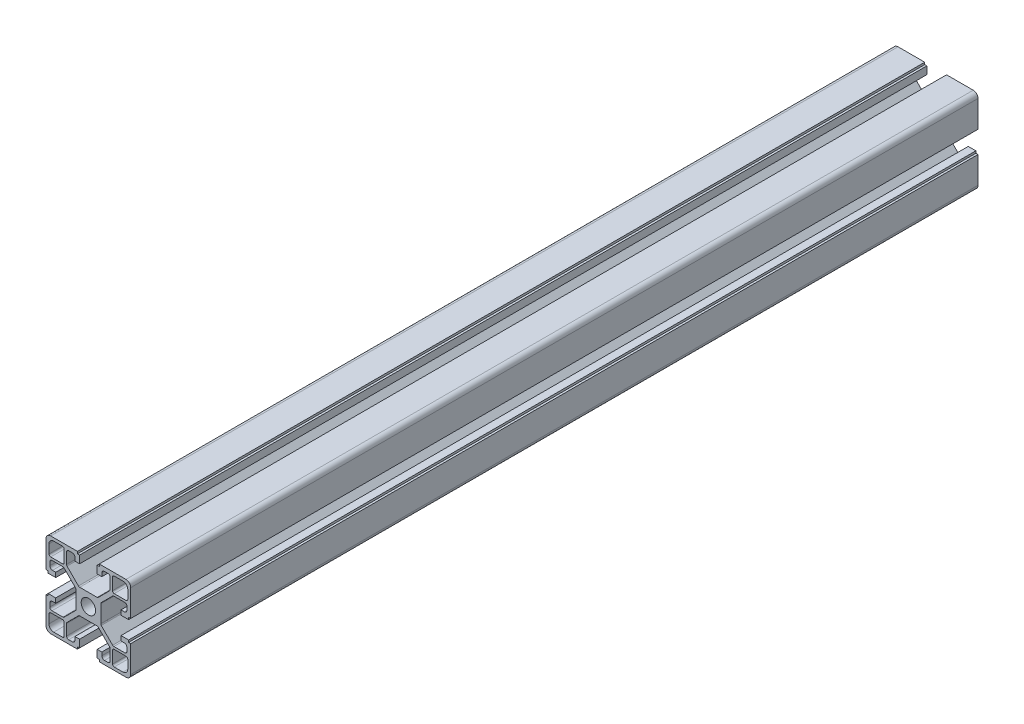
from build123d import *

# Parameters (mm, degrees)
SKETCH1_R           = 3.4
BOSS_EXTRUDE1_DEPTH = 400


with BuildPart() as part:
    # Sketch1 → Boss-Extrude1 (new body)
    with BuildSketch(Plane.XY):
        with BuildLine():
            Line((20, 17.75), (20, 5.15))
            Line((20, 5.15), (19, 5.15))
            Line((19, 5.15), (19, 4.15))
            Line((19, 4.15), (15.4, 4.15))
            Line((15.4, 4.15), (15.4, 6.35))
            Line((15.4, 6.35), (16.95, 6.35))
            ThreePointArc((16.95, 6.35), (17.833883476, 6.716116524), (18.2, 7.6))
            Line((18.2, 7.6), (18.2, 9.3))
            ThreePointArc((18.2, 9.3), (17.907106781, 10.007106781), (17.2, 10.3))
            Line((17.2, 10.3), (12.03669957, 10.3))
            ThreePointArc((12.03669957, 10.3), (11.73040037, 10.239040459), (11.470780817, 10.065452001))
            Line((11.470780817, 10.065452001), (6.084081247, 4.674305984))
            ThreePointArc((6.084081247, 4.674305984), (5.910833239, 4.414848262), (5.85, 4.108853983))
            Line((5.85, 4.108853983), (5.85, -4.108853983))
            ThreePointArc((5.85, -4.108853983), (5.910833239, -4.414848262), (6.084081247, -4.674305984))
            Line((6.084081247, -4.674305984), (11.470780817, -10.065452001))
            ThreePointArc((11.470780817, -10.065452001), (11.73040037, -10.239040459), (12.03669957, -10.3))
            Line((12.03669957, -10.3), (17.2, -10.3))
            ThreePointArc((17.2, -10.3), (17.907106781, -10.007106781), (18.2, -9.3))
            Line((18.2, -9.3), (18.2, -7.6))
            ThreePointArc((18.2, -7.6), (17.833883476, -6.716116524), (16.95, -6.35))
            Line((16.95, -6.35), (15.4, -6.35))
            Line((15.4, -6.35), (15.4, -4.15))
            Line((15.4, -4.15), (19, -4.15))
            Line((19, -4.15), (19, -5.15))
            Line((19, -5.15), (20, -5.15))
            Line((20, -5.15), (20, -17.75))
            ThreePointArc((20, -17.75), (19.340990258, -19.340990258), (17.75, -20))
            Line((17.75, -20), (5.15, -20))
            Line((5.15, -20), (5.15, -19))
            Line((5.15, -19), (4.15, -19))
            Line((4.15, -19), (4.15, -15.4))
            Line((4.15, -15.4), (6.35, -15.4))
            Line((6.35, -15.4), (6.35, -16.95))
            ThreePointArc((6.35, -16.95), (6.716116524, -17.833883476), (7.6, -18.2))
            Line((7.6, -18.2), (9.3, -18.2))
            ThreePointArc((9.3, -18.2), (10.007106781, -17.907106781), (10.3, -17.2))
            Line((10.3, -17.2), (10.3, -12.054477022))
            ThreePointArc((10.3, -12.054477022), (10.239166761, -11.748482743), (10.065918753, -11.489025021))
            Line((10.065918753, -11.489025021), (4.665899173, -6.084547999))
            ThreePointArc((4.665899173, -6.084547999), (4.406279619, -5.910959541), (4.09998042, -5.85))
            Line((4.09998042, -5.85), (-4.09998042, -5.85))
            ThreePointArc((-4.09998042, -5.85), (-4.406279619, -5.910959541), (-4.665899173, -6.084547999))
            Line((-4.665899173, -6.084547999), (-10.065918753, -11.489025021))
            ThreePointArc((-10.065918753, -11.489025021), (-10.239166761, -11.748482743), (-10.3, -12.054477022))
            Line((-10.3, -12.054477022), (-10.3, -17.2))
            ThreePointArc((-10.3, -17.2), (-10.007106781, -17.907106781), (-9.3, -18.2))
            Line((-9.3, -18.2), (-7.6, -18.2))
            ThreePointArc((-7.6, -18.2), (-6.716116524, -17.833883476), (-6.35, -16.95))
            Line((-6.35, -16.95), (-6.35, -15.4))
            Line((-6.35, -15.4), (-4.15, -15.4))
            Line((-4.15, -15.4), (-4.15, -19))
            Line((-4.15, -19), (-5.15, -19))
            Line((-5.15, -19), (-5.15, -20))
            Line((-5.15, -20), (-17.75, -20))
            ThreePointArc((-17.75, -20), (-19.340990258, -19.340990258), (-20, -17.75))
            Line((-20, -17.75), (-20, -5.15))
            Line((-20, -5.15), (-19, -5.15))
            Line((-19, -5.15), (-19, -4.15))
            Line((-19, -4.15), (-15.4, -4.15))
            Line((-15.4, -4.15), (-15.4, -6.35))
            Line((-15.4, -6.35), (-16.95, -6.35))
            ThreePointArc((-16.95, -6.35), (-17.833883476, -6.716116524), (-18.2, -7.6))
            Line((-18.2, -7.6), (-18.2, -9.3))
            ThreePointArc((-18.2, -9.3), (-17.907106781, -10.007106781), (-17.2, -10.3))
            Line((-17.2, -10.3), (-12.03669957, -10.3))
            ThreePointArc((-12.03669957, -10.3), (-11.73040037, -10.239040459), (-11.470780817, -10.065452001))
            Line((-11.470780817, -10.065452001), (-6.084081247, -4.674305984))
            ThreePointArc((-6.084081247, -4.674305984), (-5.910833239, -4.414848262), (-5.85, -4.108853983))
            Line((-5.85, -4.108853983), (-5.85, 4.108853983))
            ThreePointArc((-5.85, 4.108853983), (-5.910833239, 4.414848262), (-6.084081247, 4.674305984))
            Line((-6.084081247, 4.674305984), (-11.470780817, 10.065452001))
            ThreePointArc((-11.470780817, 10.065452001), (-11.73040037, 10.239040459), (-12.03669957, 10.3))
            Line((-12.03669957, 10.3), (-17.2, 10.3))
            ThreePointArc((-17.2, 10.3), (-17.907106781, 10.007106781), (-18.2, 9.3))
            Line((-18.2, 9.3), (-18.2, 7.6))
            ThreePointArc((-18.2, 7.6), (-17.833883476, 6.716116524), (-16.95, 6.35))
            Line((-16.95, 6.35), (-15.4, 6.35))
            Line((-15.4, 6.35), (-15.4, 4.15))
            Line((-15.4, 4.15), (-19, 4.15))
            Line((-19, 4.15), (-19, 5.15))
            Line((-19, 5.15), (-20, 5.15))
            Line((-20, 5.15), (-20, 17.75))
            ThreePointArc((-20, 17.75), (-19.340990258, 19.340990258), (-17.75, 20))
            Line((-17.75, 20), (-5.15, 20))
            Line((-5.15, 20), (-5.15, 19))
            Line((-5.15, 19), (-4.15, 19))
            Line((-4.15, 19), (-4.15, 15.4))
            Line((-4.15, 15.4), (-6.35, 15.4))
            Line((-6.35, 15.4), (-6.35, 16.95))
            ThreePointArc((-6.35, 16.95), (-6.716116524, 17.833883476), (-7.6, 18.2))
            Line((-7.6, 18.2), (-9.3, 18.2))
            ThreePointArc((-9.3, 18.2), (-10.007106781, 17.907106781), (-10.3, 17.2))
            Line((-10.3, 17.2), (-10.3, 12.054477022))
            ThreePointArc((-10.3, 12.054477022), (-10.239166761, 11.748482743), (-10.065918753, 11.489025021))
            Line((-10.065918753, 11.489025021), (-4.665899173, 6.084547999))
            ThreePointArc((-4.665899173, 6.084547999), (-4.406279619, 5.910959541), (-4.09998042, 5.85))
            Line((-4.09998042, 5.85), (4.09998042, 5.85))
            ThreePointArc((4.09998042, 5.85), (4.406279619, 5.910959541), (4.665899173, 6.084547999))
            Line((4.665899173, 6.084547999), (10.065918753, 11.489025021))
            ThreePointArc((10.065918753, 11.489025021), (10.239166761, 11.748482743), (10.3, 12.054477022))
            Line((10.3, 12.054477022), (10.3, 17.2))
            ThreePointArc((10.3, 17.2), (10.007106781, 17.907106781), (9.3, 18.2))
            Line((9.3, 18.2), (7.6, 18.2))
            ThreePointArc((7.6, 18.2), (6.716116524, 17.833883476), (6.35, 16.95))
            Line((6.35, 16.95), (6.35, 15.4))
            Line((6.35, 15.4), (4.15, 15.4))
            Line((4.15, 15.4), (4.15, 19))
            Line((4.15, 19), (5.15, 19))
            Line((5.15, 19), (5.15, 20))
            Line((5.15, 20), (17.75, 20))
            ThreePointArc((17.75, 20), (19.340990258, 19.340990258), (20, 17.75))
        make_face()
        Circle(SKETCH1_R, mode=Mode.SUBTRACT)
        with BuildLine():
            Line((18.6, 16.35), (18.6, 12.2))
            ThreePointArc((18.6, 12.2), (18.365685425, 11.634314575), (17.8, 11.4))
            Line((17.8, 11.4), (12.2, 11.4))
            ThreePointArc((12.2, 11.4), (11.634314575, 11.634314575), (11.4, 12.2))
            Line((11.4, 12.2), (11.4, 17.8))
            ThreePointArc((11.4, 17.8), (11.634314575, 18.365685425), (12.2, 18.6))
            Line((12.2, 18.6), (16.35, 18.6))
            ThreePointArc((16.35, 18.6), (17.940990258, 17.940990258), (18.6, 16.35))
        make_face(mode=Mode.SUBTRACT)
        with BuildLine():
            Line((-12.2, 18.6), (-16.35, 18.6))
            ThreePointArc((-16.35, 18.6), (-17.940990258, 17.940990258), (-18.6, 16.35))
            Line((-18.6, 16.35), (-18.6, 12.2))
            ThreePointArc((-18.6, 12.2), (-18.365685425, 11.634314575), (-17.8, 11.4))
            Line((-17.8, 11.4), (-12.2, 11.4))
            ThreePointArc((-12.2, 11.4), (-11.634314575, 11.634314575), (-11.4, 12.2))
            Line((-11.4, 12.2), (-11.4, 17.8))
            ThreePointArc((-11.4, 17.8), (-11.634314575, 18.365685425), (-12.2, 18.6))
        make_face(mode=Mode.SUBTRACT)
        with BuildLine():
            Line((-18.6, -16.35), (-18.6, -12.2))
            ThreePointArc((-18.6, -12.2), (-18.365685425, -11.634314575), (-17.8, -11.4))
            Line((-17.8, -11.4), (-12.2, -11.4))
            ThreePointArc((-12.2, -11.4), (-11.634314575, -11.634314575), (-11.4, -12.2))
            Line((-11.4, -12.2), (-11.4, -17.8))
            ThreePointArc((-11.4, -17.8), (-11.634314575, -18.365685425), (-12.2, -18.6))
            Line((-12.2, -18.6), (-16.35, -18.6))
            ThreePointArc((-16.35, -18.6), (-17.940990258, -17.940990258), (-18.6, -16.35))
        make_face(mode=Mode.SUBTRACT)
        with BuildLine():
            Line((12.2, -18.6), (16.35, -18.6))
            ThreePointArc((16.35, -18.6), (17.940990258, -17.940990258), (18.6, -16.35))
            Line((18.6, -16.35), (18.6, -12.2))
            ThreePointArc((18.6, -12.2), (18.365685425, -11.634314575), (17.8, -11.4))
            Line((17.8, -11.4), (12.2, -11.4))
            ThreePointArc((12.2, -11.4), (11.634314575, -11.634314575), (11.4, -12.2))
            Line((11.4, -12.2), (11.4, -17.8))
            ThreePointArc((11.4, -17.8), (11.634314575, -18.365685425), (12.2, -18.6))
        make_face(mode=Mode.SUBTRACT)
    extrude(amount=BOSS_EXTRUDE1_DEPTH)


solid = part.part
